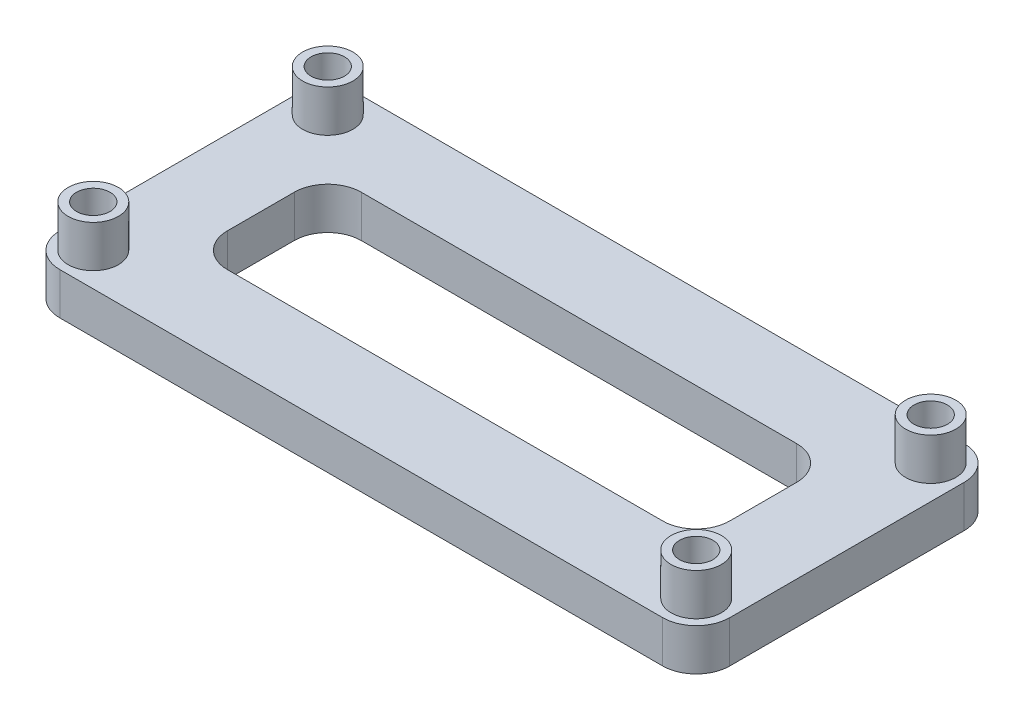
from build123d import *

# Parameters (mm, degrees)
SKETCH1_W           = 50.8
SKETCH1_H           = 22.86
SKETCH1_R           = 1.27
SKETCH1_W_2         = 38.1
SKETCH1_H_2         = 10.16
BOSS_EXTRUDE1_DEPTH = 3.175
SKETCH2_R           = 1.905
SKETCH2_R_2         = 1.27
BOSS_EXTRUDE2_DEPTH = 3.175
FILLET1_R           = 2.54


with BuildPart() as part:
    # Sketch1 → Boss-Extrude1 (new body)
    with BuildSketch(Plane(origin=(0, 0, 0), x_dir=(1, 0, 0), z_dir=(0, 1, 0))):
        with Locations((25.4, 11.43)):
            Rectangle(SKETCH1_W, SKETCH1_H)
        with Locations((2.54, 20.32)):
            Circle(SKETCH1_R, mode=Mode.SUBTRACT)
        with Locations((48.26, 20.32)):
            Circle(SKETCH1_R, mode=Mode.SUBTRACT)
        with Locations((2.54, 2.54)):
            Circle(SKETCH1_R, mode=Mode.SUBTRACT)
        with Locations((48.26, 2.54)):
            Circle(SKETCH1_R, mode=Mode.SUBTRACT)
        with Locations((25.4, 11.43)):
            Rectangle(SKETCH1_W_2, SKETCH1_H_2, mode=Mode.SUBTRACT)
    extrude(amount=BOSS_EXTRUDE1_DEPTH)

    # Sketch2 → Boss-Extrude2 (add)
    with BuildSketch(Plane(origin=(0, 3.175, 0), x_dir=(1, 0, 0), z_dir=(0, 1, 0))):
        with Locations((2.54, 20.32)):
            Circle(SKETCH2_R)
        with Locations((2.54, 20.32)):
            Circle(SKETCH2_R_2, mode=Mode.SUBTRACT)
        with Locations((2.54, 2.54)):
            Circle(SKETCH2_R)
        with Locations((2.54, 2.54)):
            Circle(SKETCH2_R_2, mode=Mode.SUBTRACT)
        with Locations((48.26, 2.54)):
            Circle(SKETCH2_R)
        with Locations((48.26, 2.54)):
            Circle(SKETCH2_R_2, mode=Mode.SUBTRACT)
        with Locations((48.26, 20.32)):
            Circle(SKETCH2_R)
        with Locations((48.26, 20.32)):
            Circle(SKETCH2_R_2, mode=Mode.SUBTRACT)
    extrude(amount=BOSS_EXTRUDE2_DEPTH)

    # Fillet1
    fillet1_edges = [part.edges().sort_by_distance(p)[0] for p in [
        (6.35, 1.5875, -16.51),
        (6.35, 1.5875, -6.35),
        (44.45, 1.5875, -6.35),
        (44.45, 1.5875, -16.51),
        (0, 1.5875, -22.86),
        (50.8, 1.5875, -22.86),
        (50.8, 1.5875, 0),
        (0, 1.5875, 0),
    ]]
    fillet(fillet1_edges, radius=FILLET1_R)


solid = part.part
